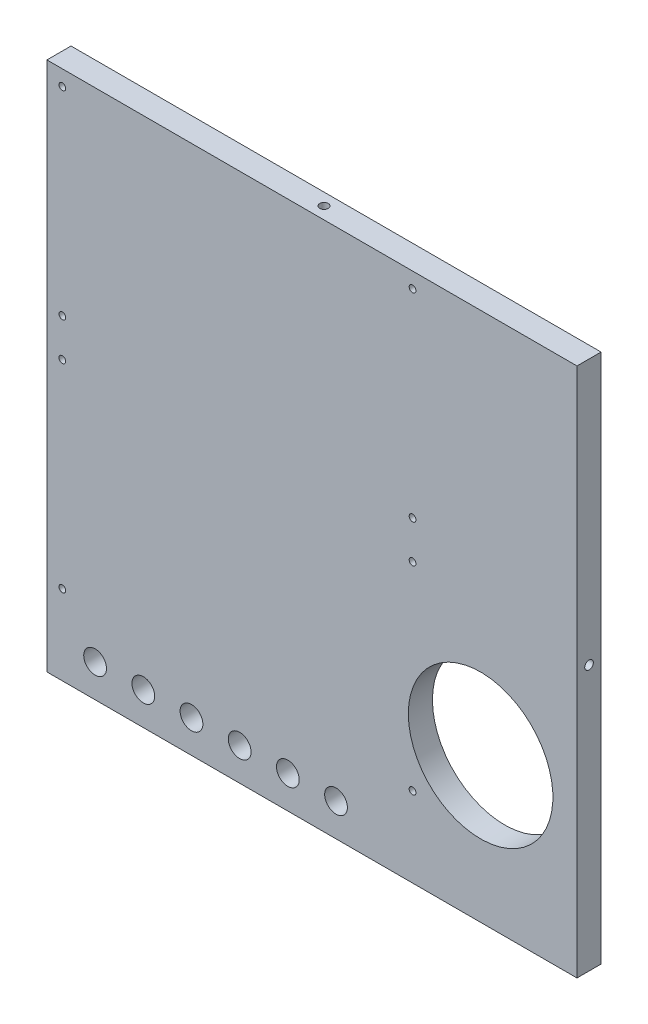
from build123d import *

# Parameters (mm, degrees)
SKETCH1_W                 = 139.7
SKETCH1_H                 = 139.7
BOSS_EXTRUDE1_DEPTH       = 6.35
F_4_40_TAPPED_HOLE1_D     = 2.2606
F_4_40_TAPPED_HOLE1_DEPTH = 7.5946
F_4_40_TAPPED_HOLE1_TIP   = 0.679152758
F_4_40_TAPPED_HOLE2_D     = 2.2606
F_4_40_TAPPED_HOLE2_DEPTH = 7.5946
F_4_40_TAPPED_HOLE2_TIP   = 0.679152758
F_4_40_TAPPED_HOLE3_D     = 2.2606
F_4_40_TAPPED_HOLE3_DEPTH = 7.5946
F_4_40_TAPPED_HOLE3_TIP   = 0.679152758
F_4_40_TAPPED_HOLE4_D     = 2.2606
F_4_40_TAPPED_HOLE4_DEPTH = 7.5946
F_4_40_TAPPED_HOLE4_TIP   = 0.679152758
SKETCH11_R                = 19.05
CUT_EXTRUDE1_DEPTH        = 7.35
F_2_56_TAPPED_HOLE1_D     = 1.778
F_2_56_TAPPED_HOLE1_DEPTH = 5.7404
F_2_56_TAPPED_HOLE1_TIP   = 0.53416509
F_2_56_TAPPED_HOLE2_D     = 1.778
F_2_56_TAPPED_HOLE2_DEPTH = 5.7404
F_2_56_TAPPED_HOLE2_TIP   = 0.53416509
F_6_0MM_DOWEL_HOLE1_D     = 6


with BuildPart() as part:
    # Sketch1 → Boss-Extrude1 (new body)
    with BuildSketch(Plane.XY):
        Rectangle(SKETCH1_W, SKETCH1_H)
    extrude(amount=BOSS_EXTRUDE1_DEPTH)

    # #4-40 Tapped Hole1
    with Locations(Plane(origin=(0, 69.85, 0), x_dir=(1, 0, 0), z_dir=(0, 1, 0))):
        with Locations((0, -3.175)):
            Hole(F_4_40_TAPPED_HOLE1_D / 2, depth=F_4_40_TAPPED_HOLE1_DEPTH)
            with Locations((0, 0, -(F_4_40_TAPPED_HOLE1_DEPTH + F_4_40_TAPPED_HOLE1_TIP / 2))):  # 118° drill point
                Cone(0, F_4_40_TAPPED_HOLE1_D / 2, F_4_40_TAPPED_HOLE1_TIP, mode=Mode.SUBTRACT)

    # #4-40 Tapped Hole2
    with Locations(Plane(origin=(69.85, 0, 0), x_dir=(0, 0, -1), z_dir=(1, 0, 0))):
        with Locations((-3.175, 0)):
            Hole(F_4_40_TAPPED_HOLE2_D / 2, depth=F_4_40_TAPPED_HOLE2_DEPTH)
            with Locations((0, 0, -(F_4_40_TAPPED_HOLE2_DEPTH + F_4_40_TAPPED_HOLE2_TIP / 2))):  # 118° drill point
                Cone(0, F_4_40_TAPPED_HOLE2_D / 2, F_4_40_TAPPED_HOLE2_TIP, mode=Mode.SUBTRACT)

    # #4-40 Tapped Hole3
    with Locations(Plane(origin=(0, -69.85, 0), x_dir=(-1, 0, 0), z_dir=(0, -1, 0))):
        with Locations((0, -3.175)):
            Hole(F_4_40_TAPPED_HOLE3_D / 2, depth=F_4_40_TAPPED_HOLE3_DEPTH)
            with Locations((0, 0, -(F_4_40_TAPPED_HOLE3_DEPTH + F_4_40_TAPPED_HOLE3_TIP / 2))):  # 118° drill point
                Cone(0, F_4_40_TAPPED_HOLE3_D / 2, F_4_40_TAPPED_HOLE3_TIP, mode=Mode.SUBTRACT)

    # #4-40 Tapped Hole4
    with Locations(Plane.ZY.offset(69.85)):
        with Locations((3.175, 0)):
            Hole(F_4_40_TAPPED_HOLE4_D / 2, depth=F_4_40_TAPPED_HOLE4_DEPTH)
            with Locations((0, 0, -(F_4_40_TAPPED_HOLE4_DEPTH + F_4_40_TAPPED_HOLE4_TIP / 2))):  # 118° drill point
                Cone(0, F_4_40_TAPPED_HOLE4_D / 2, F_4_40_TAPPED_HOLE4_TIP, mode=Mode.SUBTRACT)

    # Sketch11 → Cut-Extrude1 (cut, through all)
    with BuildSketch(Plane(origin=(0, 0, 0), x_dir=(-1, 0, 0), z_dir=(0, 0, -1))):
        with Locations((-44.45, -31.75)):
            Circle(SKETCH11_R)
    extrude(amount=-CUT_EXTRUDE1_DEPTH, mode=Mode.SUBTRACT)

    # #2-56 Tapped Hole1
    with Locations(Plane.XY.offset(6.35)):
        with Locations((-65.786, 65.786), (26.514, 65.786), (-65.786, 13.486), (26.514, 13.486), (-65.786, 3.486), (26.514, 3.486), (-65.786, -48.814), (26.514, -48.814)):
            Hole(F_2_56_TAPPED_HOLE1_D / 2, depth=F_2_56_TAPPED_HOLE1_DEPTH)
            with Locations((0, 0, -(F_2_56_TAPPED_HOLE1_DEPTH + F_2_56_TAPPED_HOLE1_TIP / 2))):  # 118° drill point
                Cone(0, F_2_56_TAPPED_HOLE1_D / 2, F_2_56_TAPPED_HOLE1_TIP, mode=Mode.SUBTRACT)

    # #2-56 Tapped Hole2
    with Locations(Plane(origin=(0, 0, 0), x_dir=(-1, 0, 0), z_dir=(0, 0, -1))):
        with Locations((44.45, 44.45), (44.45, -24.13), (-24.13, -24.13), (-24.13, 44.45)):
            Hole(F_2_56_TAPPED_HOLE2_D / 2, depth=F_2_56_TAPPED_HOLE2_DEPTH)
            with Locations((0, 0, -(F_2_56_TAPPED_HOLE2_DEPTH + F_2_56_TAPPED_HOLE2_TIP / 2))):  # 118° drill point
                Cone(0, F_2_56_TAPPED_HOLE2_D / 2, F_2_56_TAPPED_HOLE2_TIP, mode=Mode.SUBTRACT)

    # Ø6.0mm Dowel Hole1 (through all)
    with Locations(Plane.XY.offset(6.35)):
        with Locations((-57.15, -61.214), (-44.45, -61.214), (-31.75, -61.214), (-19.05, -61.214), (-6.35, -61.214), (6.35, -61.214)):
            Hole(F_6_0MM_DOWEL_HOLE1_D / 2)


solid = part.part
